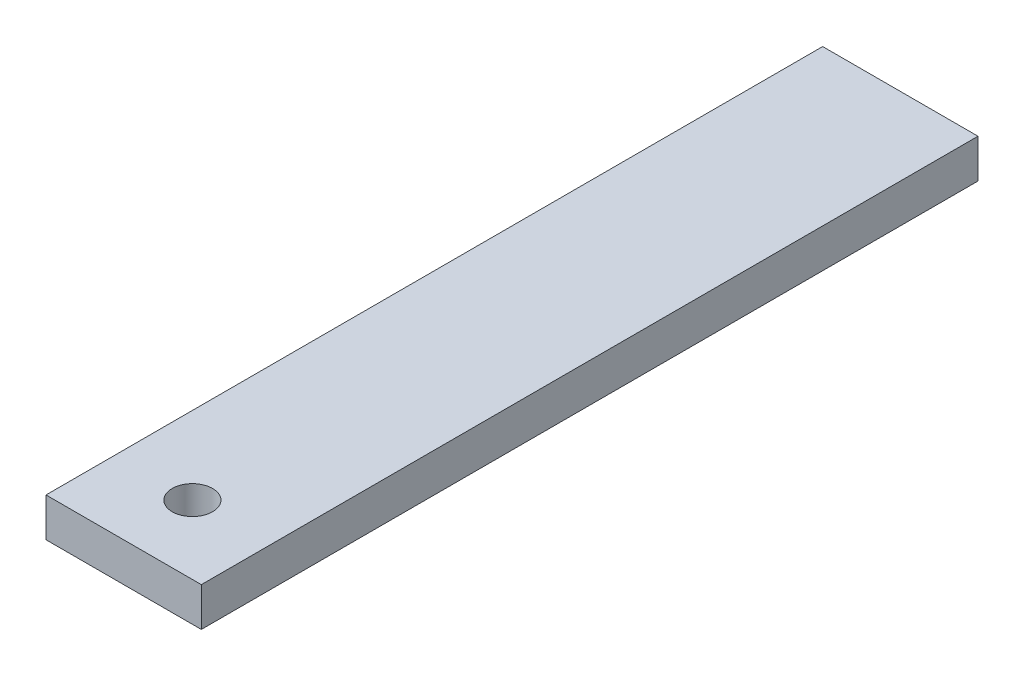
from build123d import *

# Parameters (mm, degrees)
SKETCH1_W           = 25.4
SKETCH1_H           = 127
SKETCH1_R           = 3.302
BOSS_EXTRUDE1_DEPTH = 6.35


with BuildPart() as part:
    # Sketch1 → Boss-Extrude1 (new body)
    with BuildSketch(Plane(origin=(0, 0, 0), x_dir=(1, 0, 0), z_dir=(0, 1, 0))):
        with Locations((12.7, 63.5)):
            Rectangle(SKETCH1_W, SKETCH1_H)
        with Locations((12.7, 11.23874987)):
            Circle(SKETCH1_R, mode=Mode.SUBTRACT)
    extrude(amount=BOSS_EXTRUDE1_DEPTH)


solid = part.part
